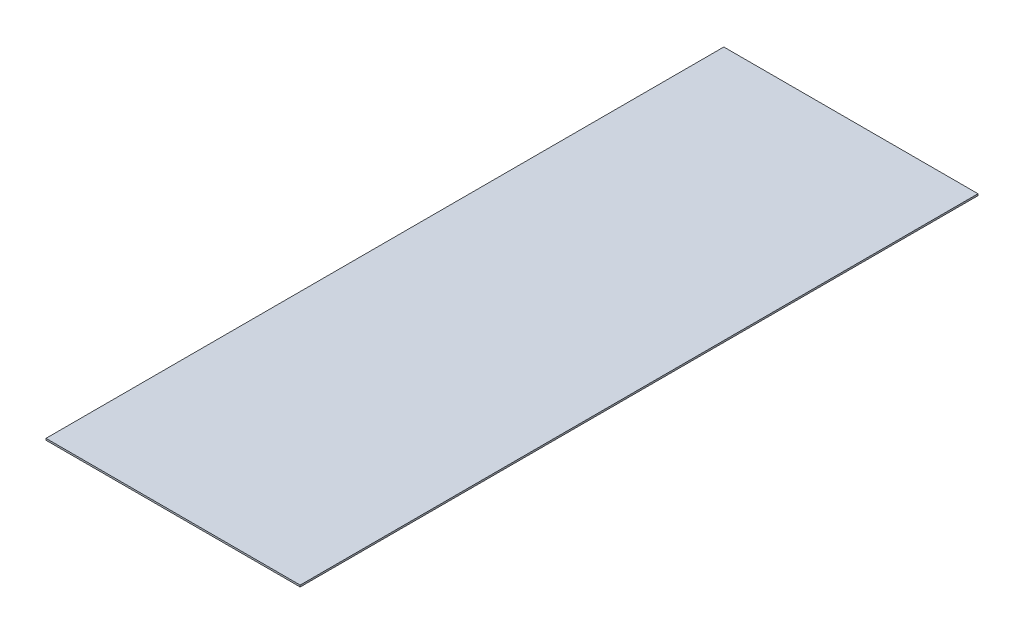
from build123d import *

# Parameters (mm, degrees)
SKETCH1_W           = 1.5
SKETCH1_H           = 4
BOSS_EXTRUDE1_DEPTH = 0.01


with BuildPart() as part:
    # Sketch1 → Boss-Extrude1 (new body)
    with BuildSketch(Plane(origin=(0, 0, 0), x_dir=(1, 0, 0), z_dir=(0, 1, 0))):
        Rectangle(SKETCH1_W, SKETCH1_H)
    extrude(amount=BOSS_EXTRUDE1_DEPTH)


solid = part.part
